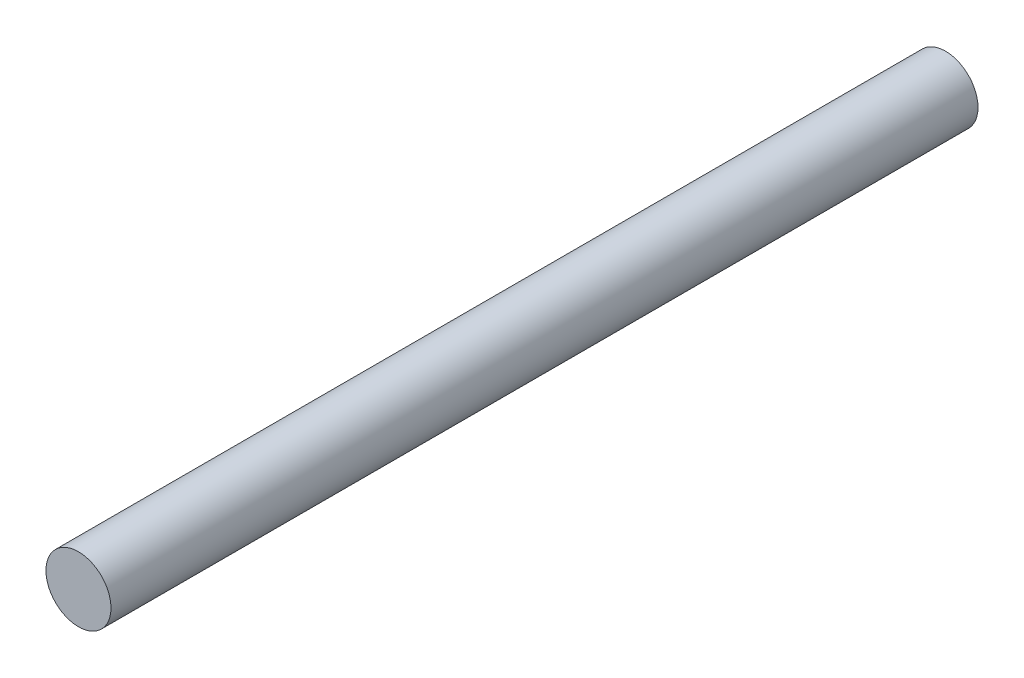
from build123d import *

# Parameters (mm, degrees)
SKETCH1_R           = 3
BOSS_EXTRUDE1_DEPTH = 80


with BuildPart() as part:
    # Sketch1 → Boss-Extrude1 (new body)
    with BuildSketch(Plane.XY):
        Circle(SKETCH1_R)
    extrude(amount=BOSS_EXTRUDE1_DEPTH)


solid = part.part
